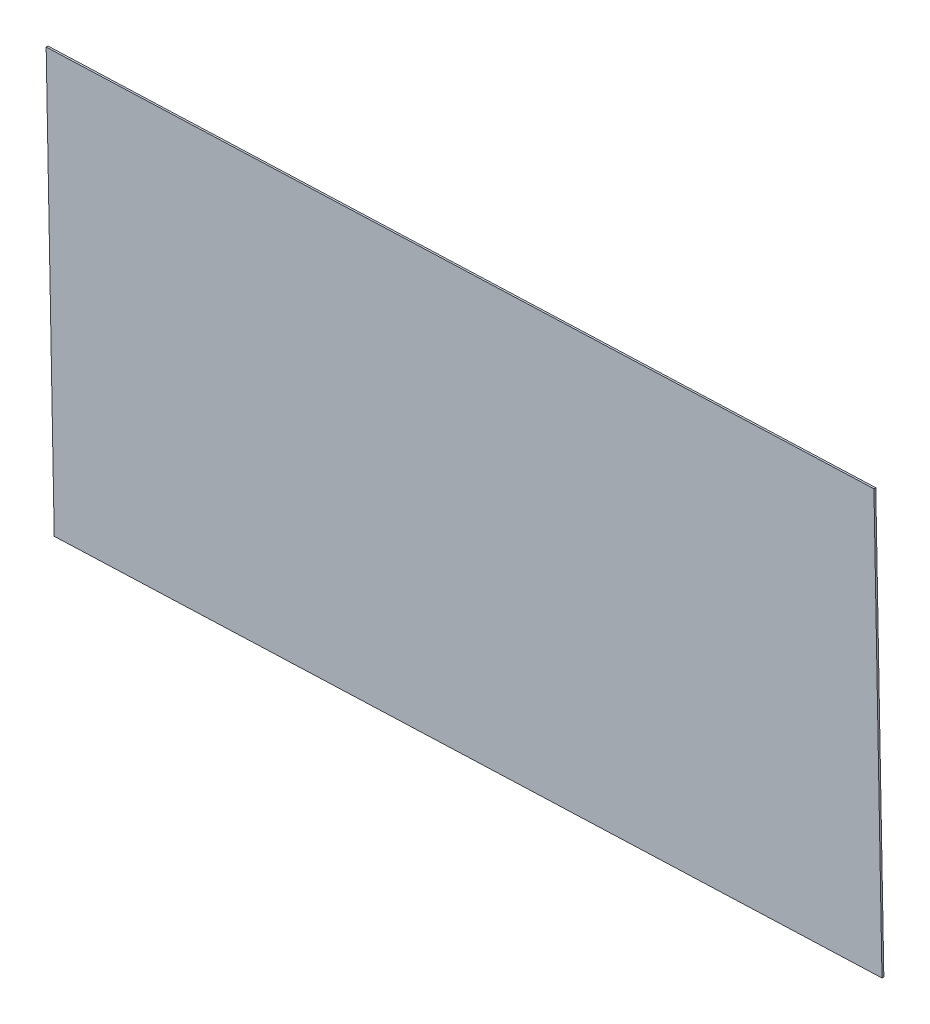
from build123d import *

# Parameters (mm, degrees)
SKETCH1_W           = 1400
SKETCH1_H           = 711.2
BOSS_EXTRUDE1_DEPTH = 3.175


with BuildPart() as part:
    # Sketch1 → Boss-Extrude1 (new body)
    with BuildSketch(Plane(origin=(7.177147891, -2.347992502, -45.898132285), x_dir=(0.999558942, 0.027772639, -0.010516791), z_dir=(0.010276918, 0.008765665, 0.99990877))):
        with Locations((88.948167176, 255.6)):
            Rectangle(SKETCH1_W, SKETCH1_H)
    extrude(amount=-BOSS_EXTRUDE1_DEPTH)


solid = part.part
